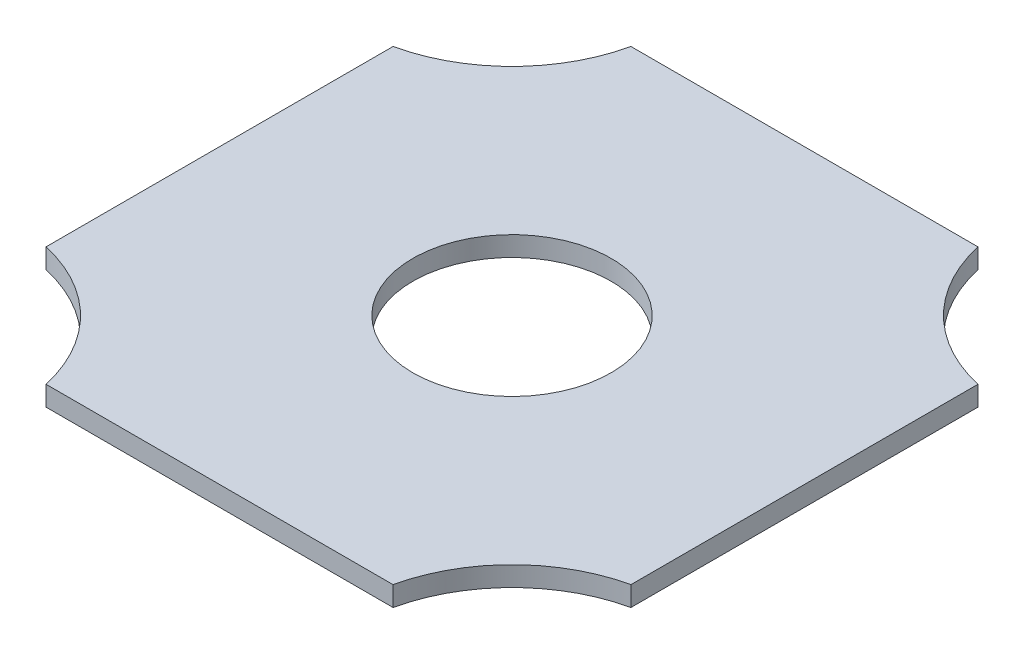
from build123d import *

# Parameters (mm, degrees)
BOSS_EXTRUDE1_DEPTH = 2
SKETCH6_R           = 10
CUT_EXTRUDE1_DEPTH  = 3


with BuildPart() as part:
    # Sketch1 → Boss-Extrude1 (new body)
    with BuildSketch(Plane(origin=(0, 0, 0), x_dir=(1, 0, 0), z_dir=(0, 1, 0))):
        with BuildLine():
            Line((-28.760538659, 18.535245878), (-28.760538659, -16.464754122))
            ThreePointArc((-28.760538659, -16.464754122), (-21.019242456, -20.723457919), (-16.760538659, -28.464754122))
            Line((-16.760538659, -28.464754122), (18.239461341, -28.464754122))
            ThreePointArc((18.239461341, -28.464754122), (22.498165139, -20.723457919), (30.239461341, -16.464754122))
            Line((30.239461341, -16.464754122), (30.239461341, 18.535245878))
            ThreePointArc((30.239461341, 18.535245878), (22.498165139, 22.793949675), (18.239461341, 30.535245878))
            Line((18.239461341, 30.535245878), (-16.760538659, 30.535245878))
            ThreePointArc((-16.760538659, 30.535245878), (-21.019242456, 22.793949675), (-28.760538659, 18.535245878))
        make_face()
    extrude(amount=BOSS_EXTRUDE1_DEPTH)

    # Sketch6 → Cut-Extrude1 (cut)
    with BuildSketch(Plane(origin=(0, 2, 0), x_dir=(1, 0, 0), z_dir=(0, 1, 0))):
        with Locations((0.739461341, 1.035245878)):
            Circle(SKETCH6_R)
    extrude(amount=-CUT_EXTRUDE1_DEPTH, mode=Mode.SUBTRACT)


solid = part.part
